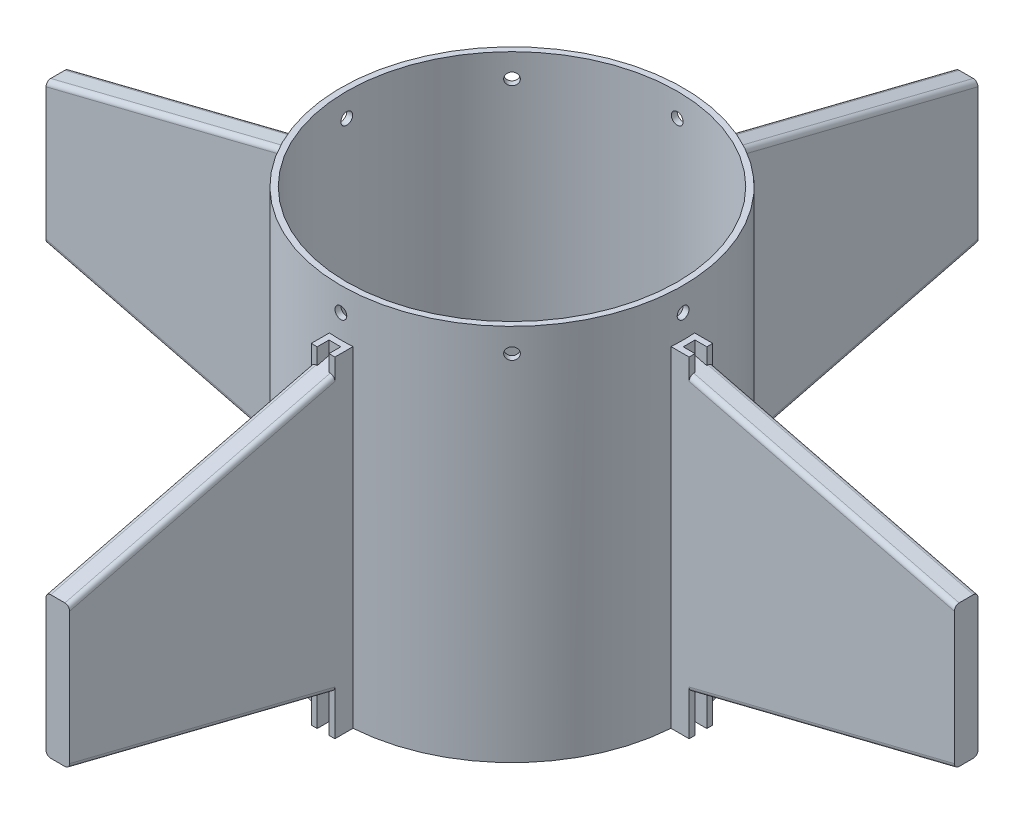
from build123d import *

# Parameters (mm, degrees)
SKETCH1_R          = 92.075
SKETCH1_R_2        = 88.9
BASE_SHELL_DEPTH   = 203.2
SKETCH2_R          = 88.9
SKETCH2_R_2        = 3.175
SKETCH2_R_3        = 3.174999998
SKETCH2_R_4        = 3.174999999
SKETCH2_R_5        = 3.175000001
BOLT_INSERT_DEPTH  = 6.35
FIN_BRACKET_DEPTH  = 177.8
CIRPATTERN1_COUNT  = 4
BASE_FIN_DEPTH     = 6.35
FIN_PATTERN_COUNT  = 4
FIN_FILLETS_R      = 2.54
SKETCH5_R          = 3.175
CUT_EXTRUDE1_DEPTH = 245.255773498
CIRPATTERN2_COUNT  = 8


with BuildPart() as part:
    # Sketch1 → Base Shell (new body)
    with BuildSketch(Plane(origin=(0, 0, 0), x_dir=(1, 0, 0), z_dir=(0, 1, 0))):
        Circle(SKETCH1_R)
        Circle(SKETCH1_R_2, mode=Mode.SUBTRACT)
    extrude(amount=BASE_SHELL_DEPTH)

    # Sketch2 → Bolt Insert (add)
    with BuildSketch(Plane.XZ):
        Circle(SKETCH2_R)
        with Locations((0, 79.375)):
            Circle(SKETCH2_R_2, mode=Mode.SUBTRACT)
        with Locations((79.375000001, -1e-09)):
            Circle(SKETCH2_R_3, mode=Mode.SUBTRACT)
        with Locations((0, -79.375000003)):
            Circle(SKETCH2_R_4, mode=Mode.SUBTRACT)
        with Locations((-79.375000001, -1e-09)):
            Circle(SKETCH2_R_5, mode=Mode.SUBTRACT)
        with BuildLine():
            ThreePointArc((-78.8035, -9.507839542), (-56.126600757, -56.126600757), (-9.507839542, -78.8035))
            ThreePointArc((-9.507839542, -78.8035), (0, -69.85), (9.507839542, -78.8035))
            ThreePointArc((9.507839542, -78.8035), (56.126600757, -56.126600757), (78.8035, -9.507839542))
            ThreePointArc((78.8035, -9.507839542), (69.85, 0), (78.8035, 9.507839542))
            ThreePointArc((78.8035, 9.507839542), (56.126600757, 56.126600757), (9.507839542, 78.8035))
            ThreePointArc((9.507839542, 78.8035), (0, 69.85), (-9.507839542, 78.8035))
            ThreePointArc((-9.507839542, 78.8035), (-56.126600757, 56.126600757), (-78.8035, 9.507839542))
            ThreePointArc((-78.8035, 9.507839542), (-69.85, 0), (-78.8035, -9.507839542))
        make_face(mode=Mode.SUBTRACT)
    extrude(amount=-BOLT_INSERT_DEPTH)

    # Sketch3 → Fin Bracket (add)
    with BuildSketch(Plane(origin=(0, 0, 0), x_dir=(1, 0, 0), z_dir=(0, 1, 0))):
        with BuildLine():
            ThreePointArc((6.35, 91.855773498), (0, 92.075), (-6.35, 91.855773498))
            Line((-6.35, 91.855773498), (-6.35, 101.6))
            Line((-6.35, 101.6), (-3.175, 101.6))
            Line((-3.175, 101.6), (-3.175, 95.25))
            Line((-3.175, 95.25), (3.175, 95.25))
            Line((3.175, 95.25), (3.175, 101.6))
            Line((3.175, 101.6), (6.35, 101.6))
            Line((6.35, 101.6), (6.35, 91.855773498))
        make_face()
    fin_bracket = extrude(amount=FIN_BRACKET_DEPTH)

    # CirPattern1: Fin Bracket ×4 about axis
    cirpattern1_axis = Axis((0, 0, 0), (0, 1, 0))
    for i in range(1, CIRPATTERN1_COUNT):
        add(fin_bracket.rotate(cirpattern1_axis, i * 360 / CIRPATTERN1_COUNT))

    # Sketch4 → Base Fin (add, symmetric)
    with BuildSketch(Plane.XY):
        Polygon((91.855773498, 171.45), (91.855773498, 19.05), (244.255773498, 57.15), (244.255773498, 133.35), align=None)
    base_fin = extrude(amount=BASE_FIN_DEPTH, both=True)

    # Fin Pattern: Base Fin ×4 about axis
    fin_pattern_axis = Axis((0, 0, 0), (0, 1, 0))
    for i in range(1, FIN_PATTERN_COUNT):
        add(base_fin.rotate(fin_pattern_axis, i * 360 / FIN_PATTERN_COUNT))

    # Fin Fillets
    fin_fillets_edges = [part.edges().sort_by_distance(p)[0] for p in [
        (172.927886749, 39.318028313, -6.35),
        (172.927886749, 151.181971687, -6.35),
        (172.927886749, 151.181971687, 6.35),
        (172.927886749, 39.318028313, 6.35),
        (6.35, 39.318028313, 172.927886749),
        (6.35, 151.181971687, 172.927886749),
        (-6.35, 151.181971687, 172.927886749),
        (-6.35, 39.318028313, 172.927886749),
        (-172.927886749, 39.318028313, 6.35),
        (-172.927886749, 151.181971687, 6.35),
        (-172.927886749, 151.181971687, -6.35),
        (-172.927886749, 39.318028313, -6.35),
        (-6.35, 39.318028313, -172.927886749),
        (-6.35, 151.181971687, -172.927886749),
        (6.35, 151.181971687, -172.927886749),
        (6.35, 39.318028313, -172.927886749),
    ]]
    fillet(fin_fillets_edges, radius=FIN_FILLETS_R)

    # Sketch5 → Cut-Extrude1 (cut, through all)
    with BuildSketch(Plane.XY):
        with Locations((0, 190.5)):
            Circle(SKETCH5_R)
    cut_extrude1 = extrude(amount=-CUT_EXTRUDE1_DEPTH, mode=Mode.SUBTRACT)

    # CirPattern2: Cut-Extrude1 ×8 about axis
    cirpattern2_axis = Axis((0, 203.2, 0), (0, 1, 0))
    for i in range(1, CIRPATTERN2_COUNT):
        add(cut_extrude1.rotate(cirpattern2_axis, i * 360 / CIRPATTERN2_COUNT), mode=Mode.SUBTRACT)


solid = part.part
